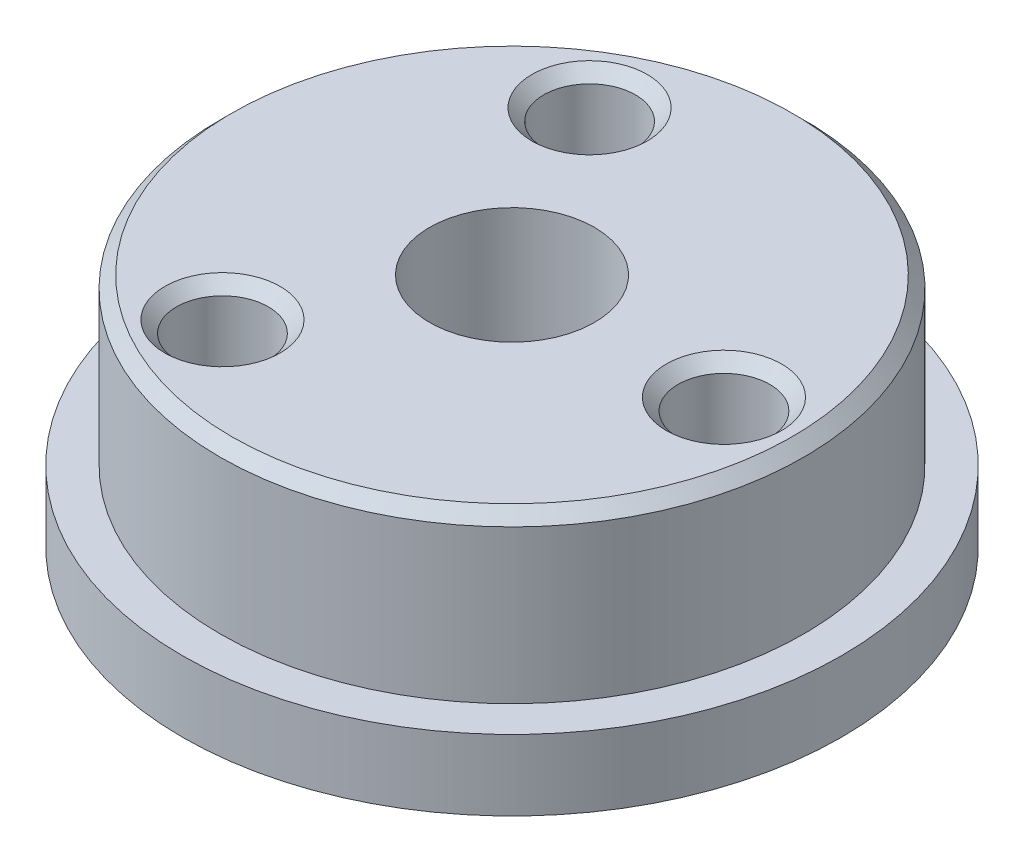
from build123d import *

# Parameters (mm, degrees)
SKETCH_1_R          = 14
EXTRUDE_1_DEPTH     = 3
SKETCH_2_R          = 12.4
EXTRUDE_2_DEPTH     = 7
SKETCH_3_R          = 1.65
CUT_EXTRUDE_1_DEPTH = 5.1
SKETCH_4_R          = 3.5
CUT_EXTRUDE_2_DEPTH = 11
SKETCH_6_R          = 1.95
CUT_EXTRUDE_4_DEPTH = 3.2
CHAMFER_1_SIZE      = 0.5


with BuildPart() as part:
    # 草图1 → 凸台-拉伸1 (new body)
    with BuildSketch(Plane(origin=(0, 0, 0), x_dir=(1, 0, 0), z_dir=(0, 1, 0))):
        Circle(SKETCH_1_R)
    extrude(amount=EXTRUDE_1_DEPTH)

    # 草图2 → 凸台-拉伸2 (add)
    with BuildSketch(Plane(origin=(0, 3, 0), x_dir=(1, 0, 0), z_dir=(0, 1, 0))):
        Circle(SKETCH_2_R)
    extrude(amount=EXTRUDE_2_DEPTH)

    # 草图3 → 切除-拉伸1 (cut)
    with BuildSketch(Plane.XZ):
        with Locations((10.5, 0)):
            Circle(SKETCH_3_R)
        with Locations((5.25, -9.09326674)):
            Circle(SKETCH_3_R)
        with Locations((-5.25, -9.09326674)):
            Circle(SKETCH_3_R)
        with Locations((-10.5, 0)):
            Circle(SKETCH_3_R)
        with Locations((-5.25, 9.09326674)):
            Circle(SKETCH_3_R)
        with Locations((5.25, 9.09326674)):
            Circle(SKETCH_3_R)
    extrude(amount=-CUT_EXTRUDE_1_DEPTH, mode=Mode.SUBTRACT)

    # 草图4 → 切除-拉伸2 (cut, through all)
    with BuildSketch(Plane.XZ):
        Circle(SKETCH_4_R)
    extrude(amount=-CUT_EXTRUDE_2_DEPTH, mode=Mode.SUBTRACT)

    # 草图6 → 切除-拉伸4 (cut)
    with BuildSketch(Plane(origin=(0, 10, 0), x_dir=(1, 0, 0), z_dir=(0, 1, 0))):
        with Locations((9, 0)):
            Circle(SKETCH_6_R)
        with Locations((-4.5, -7.794228634)):
            Circle(SKETCH_6_R)
        with Locations((-4.5, 7.794228634)):
            Circle(SKETCH_6_R)
    extrude(amount=-CUT_EXTRUDE_4_DEPTH, mode=Mode.SUBTRACT)

    # 倒角1
    chamfer_1_edges = [part.edges().sort_by_distance(p)[0] for p in [
        (7.05, 10, 0),
        (-6.45, 10, 7.794228634),
        (-6.45, 10, -7.794228634),
        (-12.4, 10, 0),
    ]]
    chamfer(chamfer_1_edges, length=CHAMFER_1_SIZE)


solid = part.part
